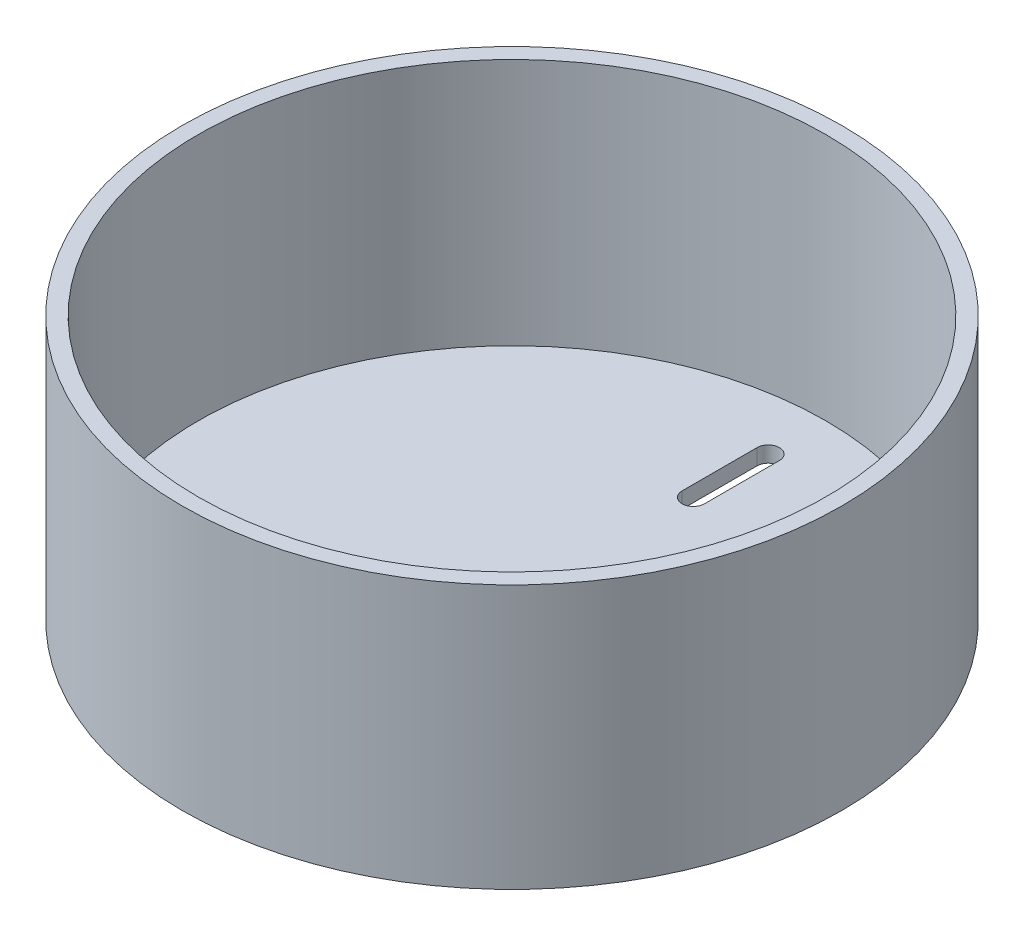
from build123d import *

# Parameters (mm, degrees)
SKETCH1_R           = 62.5
BOSS_EXTRUDE1_DEPTH = 3
SKETCH1_3_R         = 62.5
SKETCH1_3_R_2       = 59.5
BOSS_EXTRUDE2_DEPTH = 50
CUT_EXTRUDE1_DEPTH  = 50


with BuildPart() as part:
    # Sketch1 → Boss-Extrude1 (new body)
    with BuildSketch(Plane(origin=(0, 0, 0), x_dir=(1, 0, 0), z_dir=(0, 1, 0))):
        Circle(SKETCH1_R)
    extrude(amount=BOSS_EXTRUDE1_DEPTH)

    # Sketch1_3 → Boss-Extrude2 (add)
    with BuildSketch(Plane(origin=(0, 0, 0), x_dir=(1, 0, 0), z_dir=(0, 1, 0))):
        Circle(SKETCH1_3_R)
        Circle(SKETCH1_3_R_2, mode=Mode.SUBTRACT)
    extrude(amount=BOSS_EXTRUDE2_DEPTH)

    # Sketch2 → Cut-Extrude1 (cut)
    with BuildSketch(Plane.XZ):
        with BuildLine():
            Line((-2.122524784, -48.573163327), (-2.122524784, -34.368574388))
            ThreePointArc((-2.122524784, -34.368574388), (0, -32.246049604), (2.122524784, -34.368574388))
            Line((2.122524784, -34.368574388), (2.122524784, -48.573163327))
            ThreePointArc((2.122524784, -48.573163327), (0, -50.695688111), (-2.122524784, -48.573163327))
        make_face()
    extrude(amount=-CUT_EXTRUDE1_DEPTH, mode=Mode.SUBTRACT)


solid = part.part
